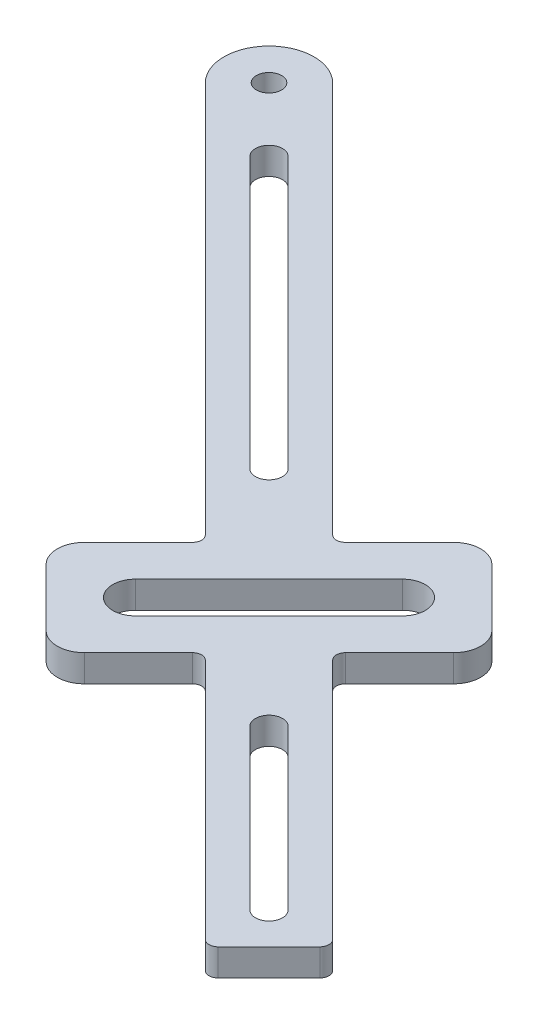
from build123d import *

# Parameters (mm, degrees)
SKETCH1_R           = 1.4
BOSS_EXTRUDE1_DEPTH = 3


with BuildPart() as part:
    # Sketch1 → Boss-Extrude1 (new body)
    with BuildSketch(Plane(origin=(0, 0, 0), x_dir=(1, 0, 0), z_dir=(0, 1, 0))):
        with BuildLine():
            Line((66.715956662, -50.018199395), (23.228889619, -6.531132352))
            ThreePointArc((23.228889619, -6.531132352), (16.157821807, -6.531132352), (16.157821807, -13.602200164))
            Line((16.157821807, -13.602200164), (59.64488885, -57.089267207))
            ThreePointArc((59.64488885, -57.089267207), (59.937782069, -57.796373988), (59.64488885, -58.503480769))
            Line((59.64488885, -58.503480769), (53.63448121, -64.513888409))
            ThreePointArc((53.63448121, -64.513888409), (52.755801554, -66.635208753), (53.63448121, -68.756529097))
            Line((53.63448121, -68.756529097), (59.998442241, -75.120490127))
            ThreePointArc((59.998442241, -75.120490127), (62.119762584, -75.999169784), (64.241082928, -75.120490127))
            Line((64.241082928, -75.120490127), (70.251490568, -69.110082487))
            ThreePointArc((70.251490568, -69.110082487), (70.958597349, -68.817189268), (71.665704131, -69.110082487))
            Line((71.665704131, -69.110082487), (98.535761816, -95.980140172))
            ThreePointArc((98.535761816, -95.980140172), (99.242868597, -96.273033391), (99.949975378, -95.980140172))
            Line((99.949975378, -95.980140172), (105.606829627, -90.323285923))
            ThreePointArc((105.606829627, -90.323285923), (105.899722846, -89.616179142), (105.606829627, -88.90907236))
            Line((105.606829627, -88.90907236), (78.736771942, -62.039014675))
            ThreePointArc((78.736771942, -62.039014675), (78.443878724, -61.331907894), (78.736771942, -60.624801113))
            Line((78.736771942, -60.624801113), (84.747179582, -54.614393473))
            ThreePointArc((84.747179582, -54.614393473), (85.625859239, -52.493073129), (84.747179582, -50.371752786))
            Line((84.747179582, -50.371752786), (78.383218552, -44.007791755))
            ThreePointArc((78.383218552, -44.007791755), (76.261898208, -43.129112099), (74.140577865, -44.007791755))
            Line((74.140577865, -44.007791755), (68.130170225, -50.018199395))
            ThreePointArc((68.130170225, -50.018199395), (67.423063443, -50.311092614), (66.715956662, -50.018199395))
        make_face()
        with Locations((19.693355713, -10.066666258)):
            Circle(SKETCH1_R, mode=Mode.SUBTRACT)
        with BuildLine():
            Line((82.625859239, -70.87784944), (100.303528769, -88.55551897))
            ThreePointArc((100.303528769, -88.55551897), (100.303528769, -90.676839313), (98.182208425, -90.676839313))
            Line((98.182208425, -90.676839313), (80.504538895, -72.999169784))
            ThreePointArc((80.504538895, -72.999169784), (80.504538895, -70.87784944), (82.625859239, -70.87784944))
        make_face(mode=Mode.SUBTRACT)
        with BuildLine():
            Line((59.998442241, -65.220995191), (74.847684646, -50.371752786))
            ThreePointArc((74.847684646, -50.371752786), (78.383218552, -50.371752786), (78.383218552, -53.907286692))
            Line((78.383218552, -53.907286692), (63.533976147, -68.756529097))
            ThreePointArc((63.533976147, -68.756529097), (59.998442241, -68.756529097), (59.998442241, -65.220995191))
        make_face(mode=Mode.SUBTRACT)
        with BuildLine():
            Line((27.825083697, -16.077073898), (57.877121897, -46.129112099))
            ThreePointArc((57.877121897, -46.129112099), (57.877121897, -48.250432442), (55.755801554, -48.250432442))
            Line((55.755801554, -48.250432442), (25.703763353, -18.198394242))
            ThreePointArc((25.703763353, -18.198394242), (25.703763353, -16.077073898), (27.825083697, -16.077073898))
        make_face(mode=Mode.SUBTRACT)
    extrude(amount=BOSS_EXTRUDE1_DEPTH)


solid = part.part
